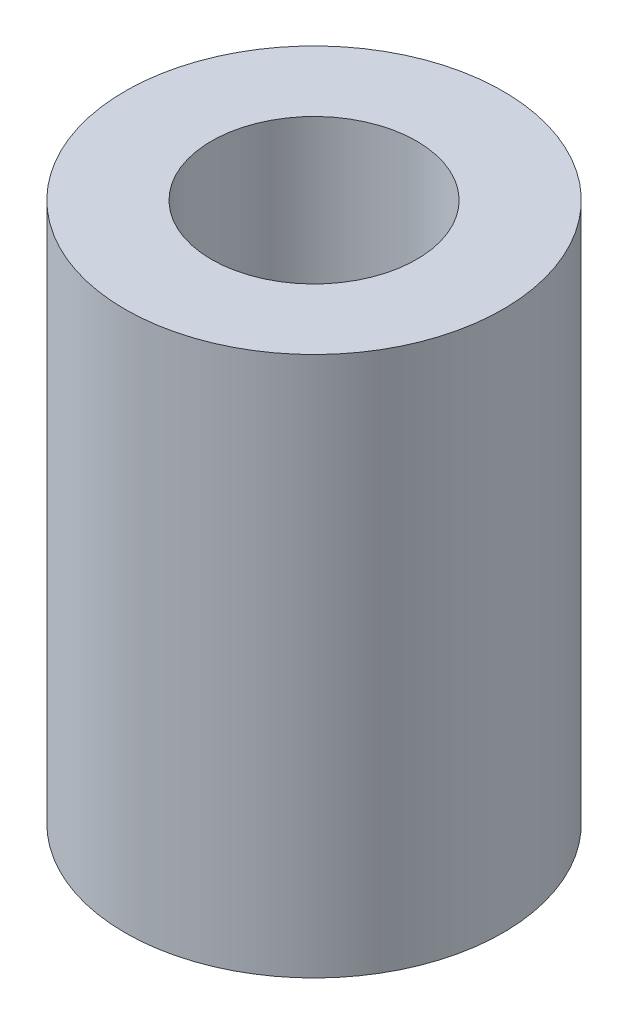
from build123d import *

# Parameters (mm, degrees)
SKETCH1_R           = 1.75
SKETCH1_R_2         = 0.95
BOSS_EXTRUDE1_DEPTH = 5


with BuildPart() as part:
    # Sketch1 → Boss-Extrude1 (new body)
    with BuildSketch(Plane(origin=(0, 0, 0), x_dir=(1, 0, 0), z_dir=(0, 1, 0))):
        Circle(SKETCH1_R)
        Circle(SKETCH1_R_2, mode=Mode.SUBTRACT)
    extrude(amount=BOSS_EXTRUDE1_DEPTH)


solid = part.part
